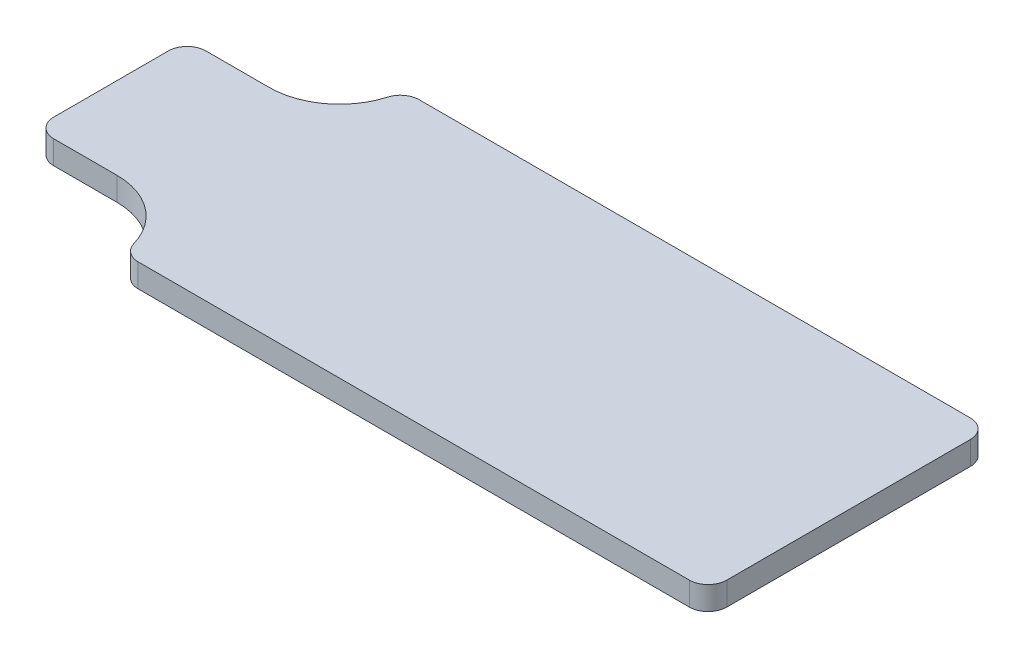
from build123d import *

# Parameters (mm, degrees)
BOSS_EXTRUDE1_DEPTH = 10
FILLET1_R           = 8


with BuildPart() as part:
    # Sketch1 → Boss-Extrude1 (new body)
    with BuildSketch(Plane(origin=(0, 0, 0), x_dir=(1, 0, 0), z_dir=(0, 1, 0))):
        with BuildLine():
            Line((-65, 92.5), (-30, 92.5))
            ThreePointArc((-30, 92.5), (-9.651474255, 100.415244642), (0, 120))
            Line((0, 120), (250, 120))
            Line((250, 120), (250, 0))
            Line((250, 0), (0, 0))
            ThreePointArc((0, 0), (-9.651474255, 19.584755358), (-30, 27.5))
            Line((-30, 27.5), (-65, 27.5))
            Line((-65, 27.5), (-65, 92.5))
        make_face()
    extrude(amount=BOSS_EXTRUDE1_DEPTH)

    # Fillet1
    fillet1_edges = [part.edges().sort_by_distance(p)[0] for p in [
        (-65, 5, -92.5),
        (0, 5, -120),
        (250, 5, -120),
        (250, 5, 0),
        (0, 5, 0),
        (-65, 5, -27.5),
    ]]
    fillet(fillet1_edges, radius=FILLET1_R)


solid = part.part
